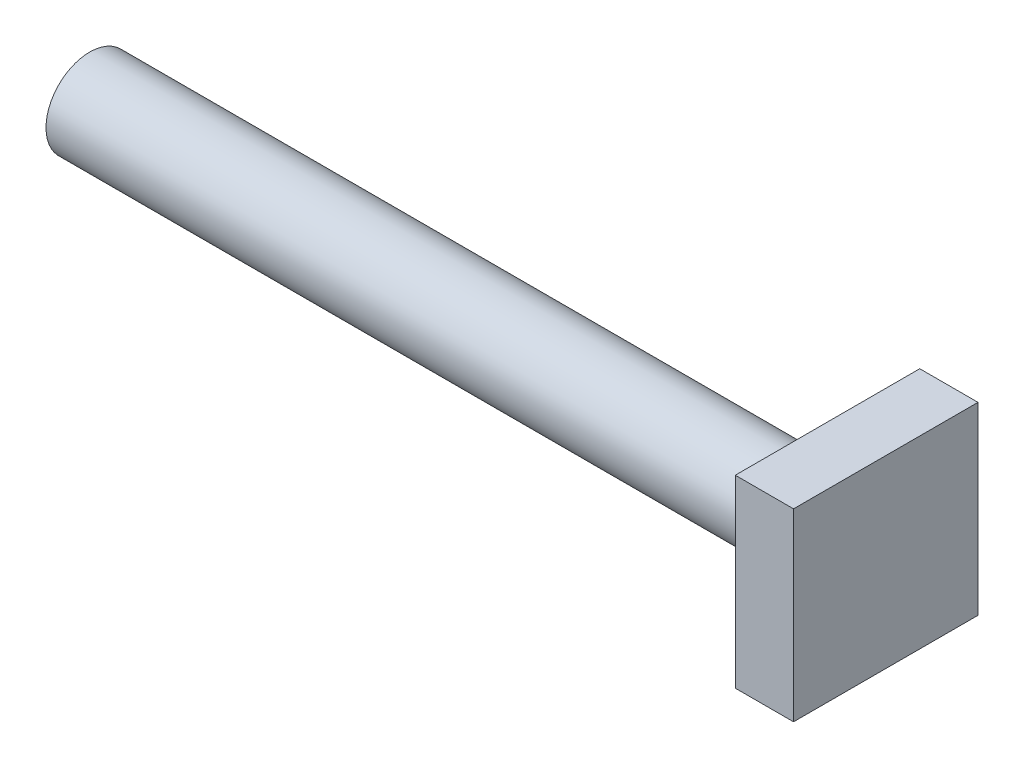
from build123d import *

# Parameters (mm, degrees)
SKETCH2_W           = 19
SKETCH2_H           = 19
BOSS_EXTRUDE1_DEPTH = 6
SKETCH3_R           = 4.5
BOSS_EXTRUDE2_DEPTH = 76


with BuildPart() as part:
    # Sketch2 → Boss-Extrude1 (new body)
    with BuildSketch(Plane(origin=(0, 0, 0), x_dir=(0, 0, -1), z_dir=(1, 0, 0))):
        with Locations((9.5, 9.5)):
            Rectangle(SKETCH2_W, SKETCH2_H)
    extrude(amount=BOSS_EXTRUDE1_DEPTH)

    # Sketch3 → Boss-Extrude2 (add)
    with BuildSketch(Plane.ZY):
        with Locations((-9.5, 9.5)):
            Circle(SKETCH3_R)
    extrude(amount=BOSS_EXTRUDE2_DEPTH)


solid = part.part
